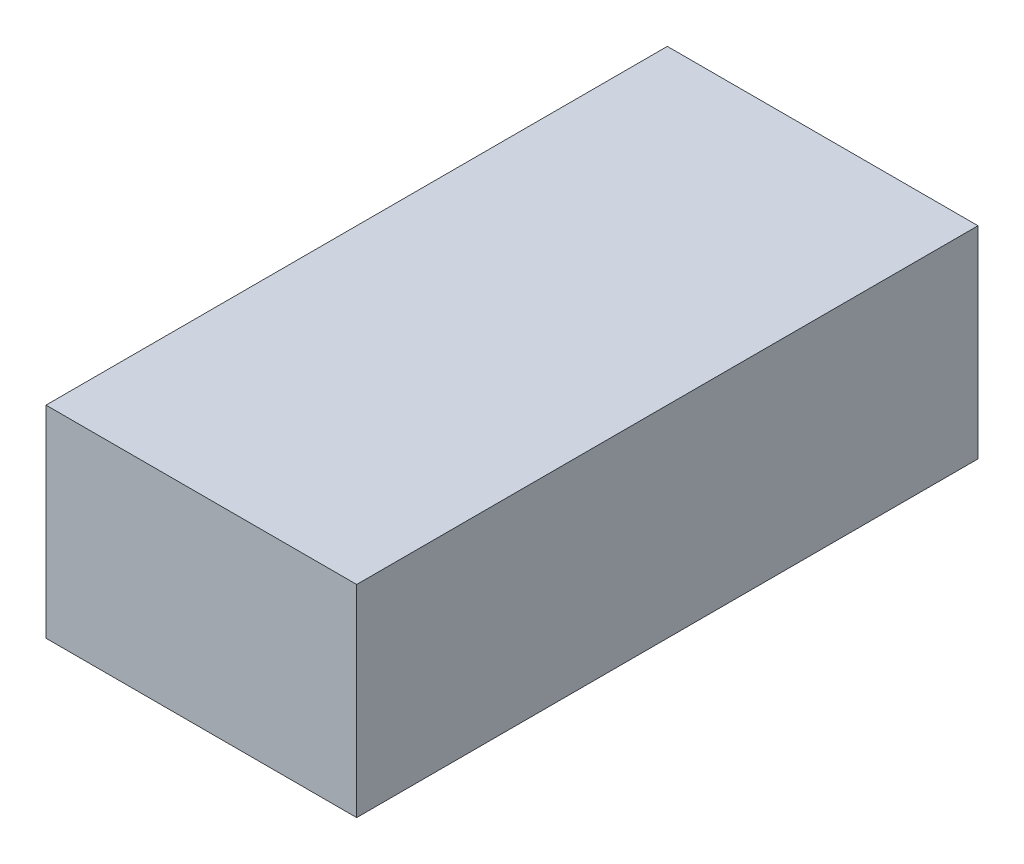
from build123d import *

# Parameters (mm, degrees)
SKETCH1_W           = 20
SKETCH1_H           = 6.5
BOSS_EXTRUDE1_DEPTH = 10


with BuildPart() as part:
    # Sketch1 → Boss-Extrude1 (new body)
    with BuildSketch(Plane(origin=(0, 0, 0), x_dir=(0, 0, -1), z_dir=(1, 0, 0))):
        Rectangle(SKETCH1_W, SKETCH1_H)
    extrude(amount=BOSS_EXTRUDE1_DEPTH)


solid = part.part
